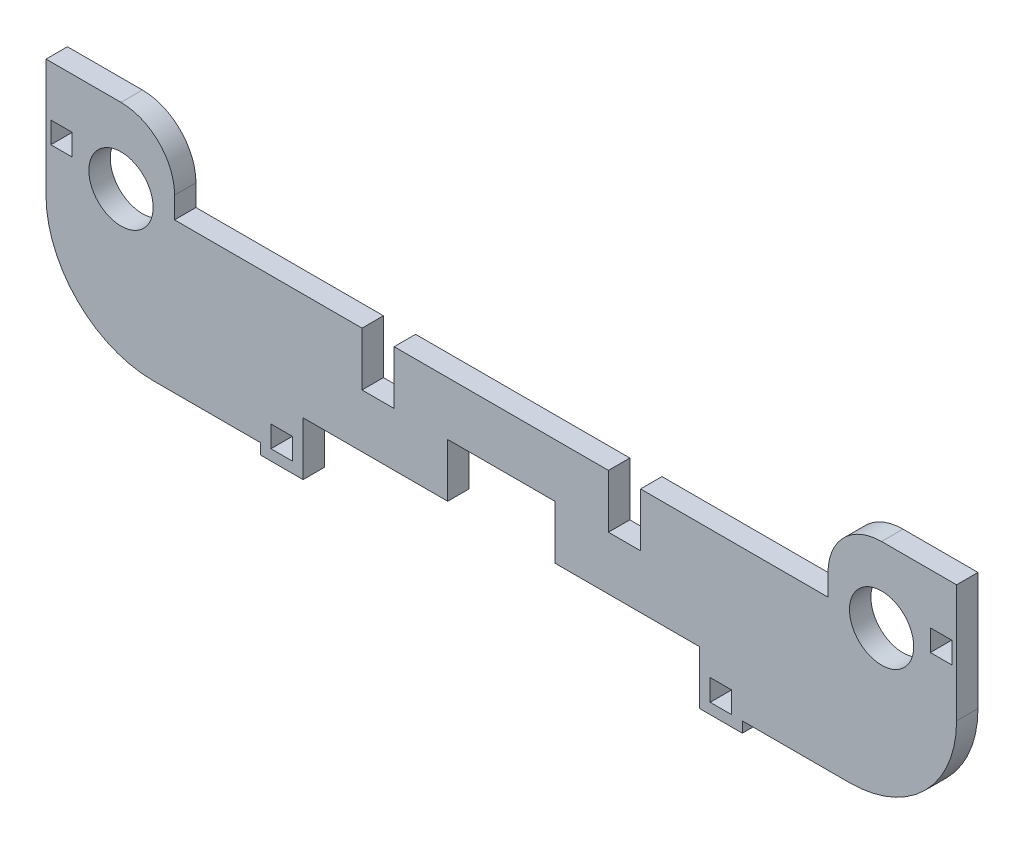
from build123d import *

# Parameters (mm, degrees)
SKETCH1_W           = 2
SKETCH1_H           = 2
SKETCH1_W_2         = 7
SKETCH1_H_2         = 5
BOSS_EXTRUDE2_DEPTH = 2
FILLET1_R           = 10
FILLET2_R           = 10
FILLET3_R           = 5
FILLET4_R           = 5


with BuildPart() as part:
    # Sketch1 → Boss-Extrude2 (new body)
    with BuildSketch(Plane.XY):
        with BuildLine():
            Line((-42.5, 0), (-35.5, 0))
            Line((-35.5, 0), (-35.5, 2))
            ThreePointArc((-35.5, 2), (-37.621320344, 7.121320344), (-32.5, 5))
            Line((-32.5, 5), (-30.5, 5))
            Line((-30.5, 5), (-30.5, 12))
            Line((-30.5, 12), (-42.5, 12))
            Line((-42.5, 12), (-42.5, 0))
        make_face()
        with Locations((-41.05, 6.3)):
            Rectangle(SKETCH1_W, SKETCH1_H, mode=Mode.SUBTRACT)
        Polygon((-18.5, -5), (-35.5, -5), (-42.5, -5), (-42.5, -9), (-22.5, -9), (-22.5, -10), (-18.5, -10), (-18.5, -9), align=None)
        with Locations((-20.5, -8)):
            Rectangle(SKETCH1_W, SKETCH1_H, mode=Mode.SUBTRACT)
        with Locations((-39, -2.5)):
            Rectangle(SKETCH1_W_2, SKETCH1_H_2)
        with BuildLine():
            Line((-35.5, 0), (-35.5, -5))
            Line((-35.5, -5), (-18.5, -5))
            Line((-18.5, -5), (-5, -5))
            Line((-5, -5), (-5, 0))
            Line((-5, 0), (-10, 0))
            Line((-10, 0), (-13, 0))
            Line((-13, 0), (-13, 5))
            Line((-13, 5), (-30.5, 5))
            Line((-30.5, 5), (-32.5, 5))
            ThreePointArc((-32.5, 5), (-33.378679656, 2.878679656), (-35.5, 2))
            Line((-35.5, 2), (-35.5, 0))
        make_face()
        Polygon((-10, 0), (-5, 0), (5, 0), (10, 0), (10, 5), (-10, 5), align=None)
        Polygon((35.5, -5), (18.5, -5), (18.5, -9), (18.5, -10), (22.5, -10), (22.5, -9), (42.5, -9), (42.5, -5), align=None)
        with Locations((20.5, -8)):
            Rectangle(SKETCH1_W, SKETCH1_H, mode=Mode.SUBTRACT)
        with Locations((39, -2.5)):
            Rectangle(SKETCH1_W_2, SKETCH1_H_2)
        with BuildLine():
            Line((35.5, 2), (35.5, 0))
            Line((35.5, 0), (42.5, 0))
            Line((42.5, 0), (42.5, 12))
            Line((42.5, 12), (30.5, 12))
            Line((30.5, 12), (30.5, 5))
            Line((30.5, 5), (32.5, 5))
            ThreePointArc((32.5, 5), (35.5, 8), (38.5, 5))
            ThreePointArc((38.5, 5), (37.621320344, 2.878679656), (35.5, 2))
        make_face()
        with Locations((41.05, 6.3)):
            Rectangle(SKETCH1_W, SKETCH1_H, mode=Mode.SUBTRACT)
        with BuildLine():
            Line((5, 0), (5, -5))
            Line((5, -5), (18.5, -5))
            Line((18.5, -5), (35.5, -5))
            Line((35.5, -5), (35.5, 0))
            Line((35.5, 0), (35.5, 2))
            ThreePointArc((35.5, 2), (33.378679656, 2.878679656), (32.5, 5))
            Line((32.5, 5), (30.5, 5))
            Line((30.5, 5), (13, 5))
            Line((13, 5), (13, 0))
            Line((13, 0), (10, 0))
            Line((10, 0), (5, 0))
        make_face()
    extrude(amount=BOSS_EXTRUDE2_DEPTH)

    # Fillet1
    fillet1_edges = [part.edges().sort_by_distance(p)[0] for p in [
        (-42.5, -9, 1),
    ]]
    fillet(fillet1_edges, radius=FILLET1_R)

    # Fillet2
    fillet2_edges = [part.edges().sort_by_distance(p)[0] for p in [
        (42.5, -9, 1),
    ]]
    fillet(fillet2_edges, radius=FILLET2_R)

    # Fillet3
    fillet3_edges = [part.edges().sort_by_distance(p)[0] for p in [
        (-30.5, 12, 1),
    ]]
    fillet(fillet3_edges, radius=FILLET3_R)

    # Fillet4
    fillet4_edges = [part.edges().sort_by_distance(p)[0] for p in [
        (30.5, 12, 1),
    ]]
    fillet(fillet4_edges, radius=FILLET4_R)


solid = part.part
